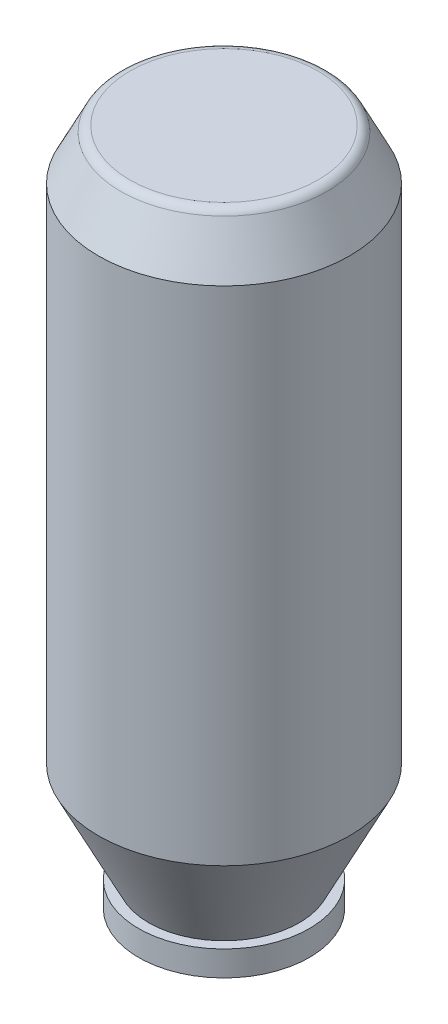
from build123d import *

# Parameters (mm, degrees)
SKETCH_3_R      = 25
EXTRUDE_2_DEPTH = 100
SKETCH_6_R      = 17
EXTRUDE_3_DEPTH = 5
FILLET_1_R      = 2


with BuildPart() as part:
    # 草图2 → 旋转1 (revolve)
    with BuildSketch(Plane(origin=(0, 0, 0), x_dir=(0, 0, -1), z_dir=(1, 0, 0))):
        Polygon((0, 0), (25, 0), (20, 10), (0, 10), align=None)
    revolve(axis=Axis((0, 0, 0), (0, 1, 0)))

    # 草图3 → 凸台-拉伸2 (add)
    with BuildSketch(Plane(origin=(0, 0, 0), x_dir=(-1, 0, 0), z_dir=(0, -1, 0))):
        Circle(SKETCH_3_R)
    extrude(amount=EXTRUDE_2_DEPTH)

    # 草图5 → 旋转2 (revolve)
    with BuildSketch(Plane(origin=(0, 0, 0), x_dir=(0, 0, -1), z_dir=(1, 0, 0))):
        Polygon((-25, -100), (0, -100), (0, -120), (-15, -120), align=None)
    revolve(axis=Axis((0, -100, 0), (0, -1, 0)))

    # 草图6 → 凸台-拉伸3 (add)
    with BuildSketch(Plane(origin=(0, -120, 0), x_dir=(-1, 0, 0), z_dir=(0, -1, 0))):
        Circle(SKETCH_6_R)
    extrude(amount=EXTRUDE_3_DEPTH)

    # 圆角1
    fillet_1_edges = [part.edges().sort_by_distance(p)[0] for p in [
        (0, 10, 20),
    ]]
    fillet(fillet_1_edges, radius=FILLET_1_R)


solid = part.part
